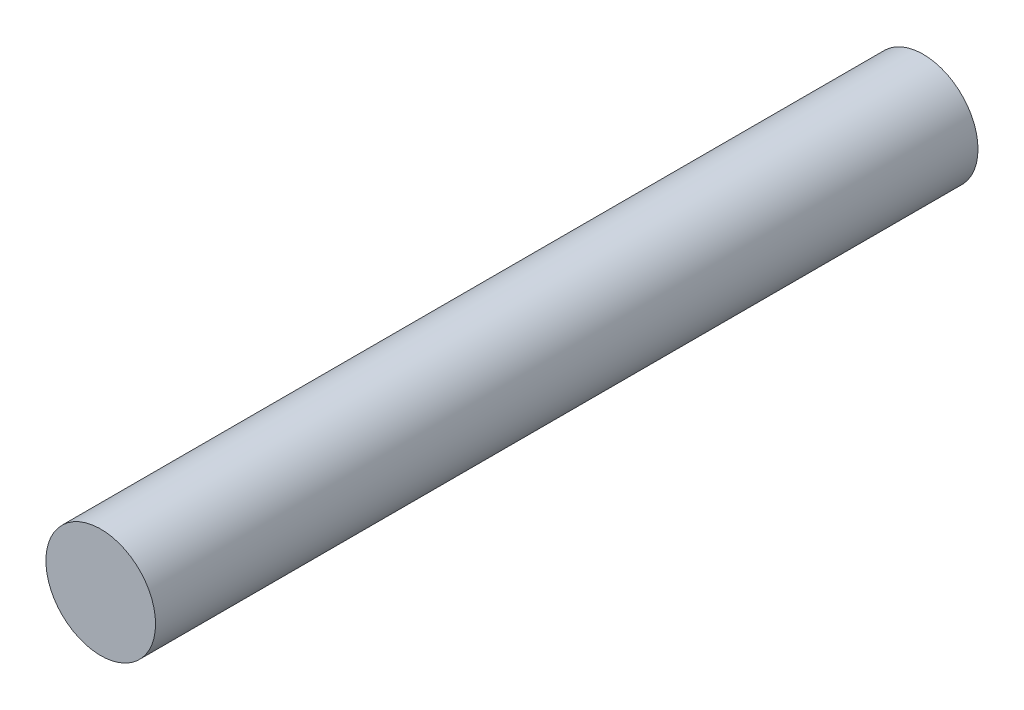
from build123d import *

# Parameters (mm, degrees)
SKETCH1_R           = 10
BOSS_EXTRUDE1_DEPTH = 150
SKETCH2_R           = 5
CUT_EXTRUDE1_DEPTH  = 123


with BuildPart() as part:
    # Sketch1 → Boss-Extrude1 (new body)
    with BuildSketch(Plane.XY):
        Circle(SKETCH1_R)
    extrude(amount=BOSS_EXTRUDE1_DEPTH)

    # Sketch2 → Cut-Extrude1 (cut)
    with BuildSketch(Plane(origin=(0, 0, 0), x_dir=(-1, 0, 0), z_dir=(0, 0, -1))):
        Circle(SKETCH2_R)
    extrude(amount=-CUT_EXTRUDE1_DEPTH, mode=Mode.SUBTRACT)


solid = part.part
